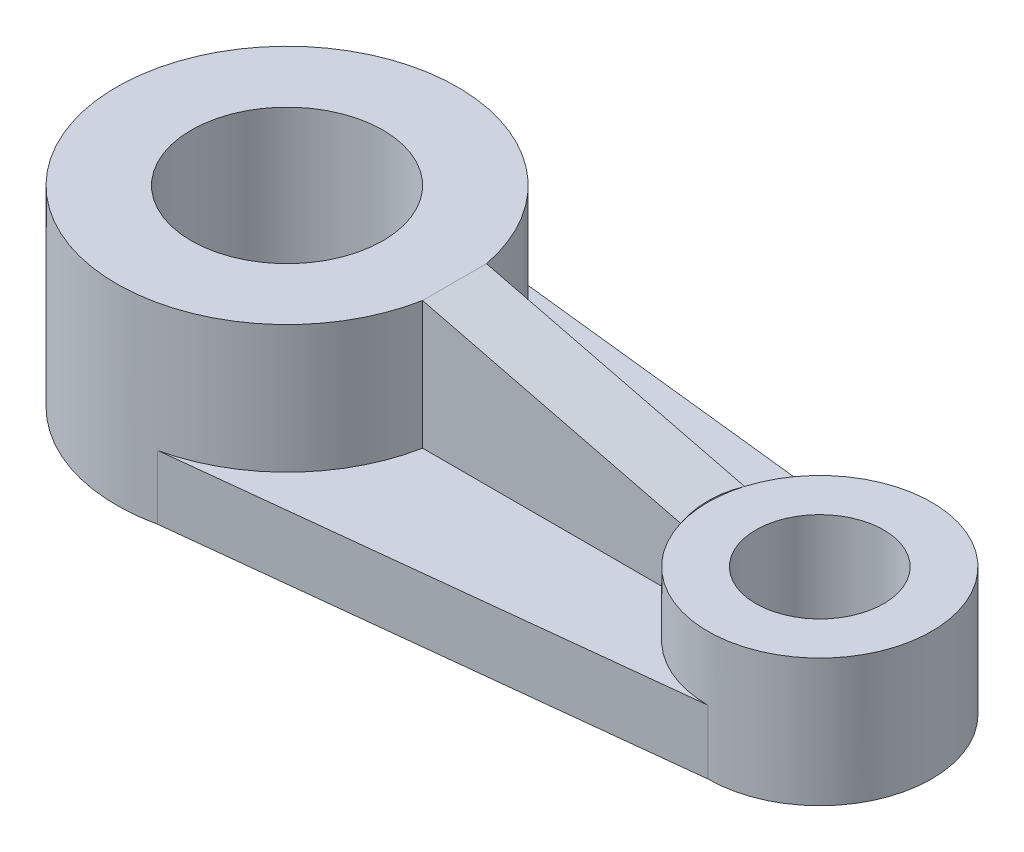
from build123d import *

# Parameters (mm, degrees)
SKETCH1_R           = 32
SKETCH1_R_2         = 18
BOSS_EXTRUDE1_DEPTH = 36
SKETCH1_6_R         = 21
SKETCH1_6_R_2       = 12
BOSS_EXTRUDE2_DEPTH = 24
BOSS_EXTRUDE3_DEPTH = 12
BOSS_EXTRUDE4_DEPTH = 36
CUT_EXTRUDE2_DEPTH  = 32


with BuildPart() as part:
    # Sketch1 → Boss-Extrude1 (new body)
    with BuildSketch(Plane(origin=(0, 0, 0), x_dir=(1, 0, 0), z_dir=(0, 1, 0))):
        with Locations(Location((0, 0, 0), (0, 0, 270))):  # turned: the seam where the file's is
            Circle(SKETCH1_R)
        with Locations(Location((0, 0, 0), (0, 0, 270))):  # turned: the seam where the file's is
            Circle(SKETCH1_R_2, mode=Mode.SUBTRACT)
    extrude(amount=BOSS_EXTRUDE1_DEPTH)



with BuildPart() as body_2:
    # Sketch1_6 → Boss-Extrude2 (new body)
    with BuildSketch(Plane(origin=(0, 0, 0), x_dir=(1, 0, 0), z_dir=(0, 1, 0))):
        with Locations(Location((100, 0, 0), (0, 0, 270))):  # turned: the seam where the file's is
            Circle(SKETCH1_6_R)
        with Locations(Location((100, 0, 0), (0, 0, 270))):  # turned: the seam where the file's is
            Circle(SKETCH1_6_R_2, mode=Mode.SUBTRACT)
    extrude(amount=BOSS_EXTRUDE2_DEPTH)


with BuildPart() as part_1:
    add(part.part)

    add(body_2.part)  # Boss-Extrude3 merges body 2
    # Sketch2 → Boss-Extrude3 (add)
    with BuildSketch(Plane(origin=(0, 0, 0), x_dir=(1, 0, 0), z_dir=(0, 1, 0))):
        with BuildLine():
            Line((100, 21), (6.955834404, 31.234858216))
            ThreePointArc((6.955834404, 31.234858216), (32, 0), (6.955834404, -31.234858216))
            Line((6.955834404, -31.234858216), (100, -21))
            ThreePointArc((100, -21), (79, 0), (100, 21))
        make_face()
    extrude(amount=BOSS_EXTRUDE3_DEPTH)

    # Sketch3 → Boss-Extrude4 (add)
    with BuildSketch(Plane(origin=(0, 0, 0), x_dir=(1, 0, 0), z_dir=(0, 1, 0))):
        with BuildLine():
            Line((31.432467291, -6), (79.875388203, -6))
            ThreePointArc((79.875388203, -6), (79, 0), (79.875388203, 6))
            Line((79.875388203, 6), (31.432467291, 6))
            ThreePointArc((31.432467291, 6), (32, 0), (31.432467291, -6))
        make_face()
    extrude(amount=BOSS_EXTRUDE4_DEPTH)

    # Sketch5 → Cut-Extrude2 (cut)
    with BuildSketch(Plane.XY.offset(6)):
        Polygon((79.875388203, 24), (31.432467291, 36), (79.875388203, 36), align=None)
    extrude(amount=-CUT_EXTRUDE2_DEPTH, mode=Mode.SUBTRACT)


solid = part_1.part
